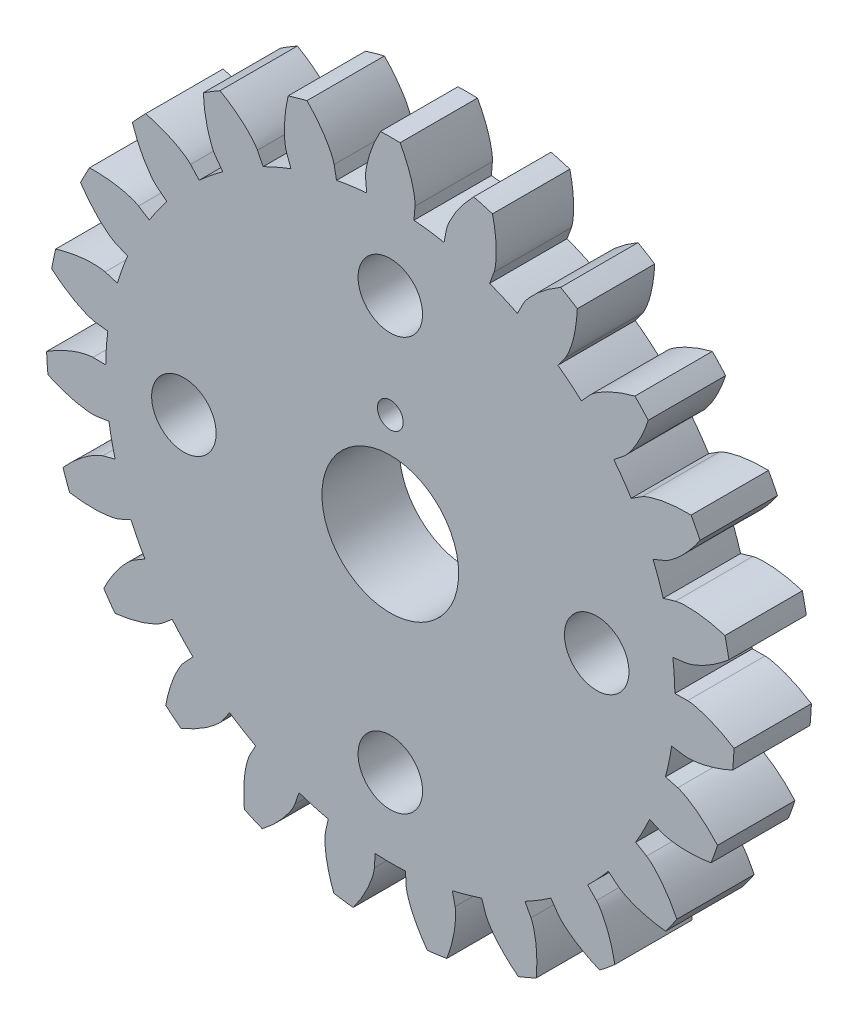
from build123d import *

# Parameters (mm, degrees)
BOSS_EXTRUDE1_DEPTH = 3
SKETCH2_R           = 2.65
SKETCH2_R_2         = 1.25
SKETCH2_R_3         = 0.5
CUT_EXTRUDE1_DEPTH  = 4.0000001


with BuildPart() as part:
    # Model → Boss-Extrude1 (new body)
    with BuildSketch(Plane.XY):
        with BuildLine():
            Line((-3.538746102, -10.448013917), (-3.69731571, -10.916184682))
            add(Edge.make_bspline(
                [(-3.69731571, -10.916184682), (-3.706904602, -10.940308677), (-3.747498158, -11.035961617), (-3.865200891, -11.238603118), (-4.093466254, -11.554754655), (-4.463378416, -11.956665333), (-4.776092769, -12.231743922), (-4.961450629, -12.373903165)],
                knots=[34.58462916, 34.58462916, 34.58462916, 34.58462916, 34.662508722, 34.896108405, 35.285436008, 35.830492648, 36.531278694, 36.531278694, 36.531278694, 36.531278694], degree=3))
            ThreePointArc((-4.961450629, -12.373903165), (-5.31129279, -12.227822405), (-5.656839729, -12.071853054))
            add(Edge.make_bspline(
                [(-5.656839729, -12.071853054), (-5.679461232, -11.839355625), (-5.691868071, -11.423056974), (-5.650622002, -10.878386466), (-5.57537033, -10.495771704), (-5.507611003, -10.271436721), (-5.465411654, -10.176481275), (-5.454325899, -10.153007459)],
                knots=[37.289536731, 37.289536731, 37.289536731, 37.289536731, 37.990322777, 38.535379417, 38.92470702, 39.158306703, 39.236186265, 39.236186265, 39.236186265, 39.236186265], degree=3))
            Line((-5.454325899, -10.153007459), (-5.220402051, -9.717567659))
            ThreePointArc((-5.220402051, -9.717567659), (-5.731548399, -9.425129799), (-6.226360217, -9.105830947))
            Line((-6.226360217, -9.105830947), (-6.505360594, -9.513859102))
            add(Edge.make_bspline(
                [(-6.505360594, -9.513859102), (-6.521102481, -9.534501462), (-6.585997572, -9.615655321), (-6.75400759, -9.779026508), (-7.059104919, -10.02186903), (-7.523733938, -10.309074663), (-7.899067309, -10.489583269), (-8.115905702, -10.576461909)],
                knots=[41.402695863, 41.402695863, 41.402695863, 41.402695863, 41.480575425, 41.714175107, 42.103502711, 42.64855935, 43.349345397, 43.349345397, 43.349345397, 43.349345397], degree=3))
            ThreePointArc((-8.115905702, -10.576461909), (-8.413362649, -10.341411935), (-8.704015743, -10.097998902))
            add(Edge.make_bspline(
                [(-8.704015743, -10.097998902), (-8.663071323, -9.8680199), (-8.562702051, -9.463811408), (-8.376035154, -8.950466815), (-8.200345791, -8.602343105), (-8.074574309, -8.404608319), (-8.008321154, -8.324559327), (-7.991313329, -8.304946884)],
                knots=[44.107603434, 44.107603434, 44.107603434, 44.107603434, 44.80838948, 45.35344612, 45.742773723, 45.976373406, 46.054252968, 46.054252968, 46.054252968, 46.054252968], degree=3))
            Line((-7.991313329, -8.304946884), (-7.64858376, -7.948766272))
            ThreePointArc((-7.64858376, -7.948766272), (-8.061876625, -7.529267167), (-8.452193678, -7.088310152))
            Line((-8.452193678, -7.088310152), (-8.830932644, -7.405934115))
            add(Edge.make_bspline(
                [(-8.830932644, -7.405934115), (-8.85166002, -7.42156389), (-8.936043675, -7.482199858), (-9.141900445, -7.594184238), (-9.501202065, -7.745707227), (-10.026088532, -7.896907086), (-10.436204162, -7.969458212), (-10.668441176, -7.994612858)],
                knots=[48.220762566, 48.220762566, 48.220762566, 48.220762566, 48.298642127, 48.53224181, 48.921569414, 49.466626053, 50.167412099, 50.167412099, 50.167412099, 50.167412099], degree=3))
            ThreePointArc((-10.668441176, -7.994612858), (-10.891451889, -7.688026251), (-11.105654727, -7.375222367))
            add(Edge.make_bspline(
                [(-11.105654727, -7.375222367), (-11.004181046, -7.164818282), (-10.798479592, -6.802678243), (-10.480236096, -6.358731987), (-10.217139118, -6.070918071), (-10.042683378, -5.914448566), (-9.957290109, -5.855242896), (-9.935621607, -5.840946392)],
                knots=[50.925670137, 50.925670137, 50.925670137, 50.925670137, 51.626456183, 52.171512822, 52.560840426, 52.794440109, 52.872319671, 52.872319671, 52.872319671, 52.872319671], degree=3))
            Line((-9.935621607, -5.840946392), (-9.509505001, -5.590441255))
            ThreePointArc((-9.509505001, -5.590441255), (-9.794292341, -5.074993233), (-10.051166601, -4.54508182))
            Line((-10.051166601, -4.54508182), (-10.501554817, -4.748744875))
            add(Edge.make_bspline(
                [(-10.501554817, -4.748744875), (-10.52573043, -4.758202876), (-10.623344298, -4.79382386), (-10.851780364, -4.846116064), (-11.238638519, -4.895081752), (-11.784854006, -4.899062036), (-12.199335495, -4.858274897), (-12.429747173, -4.819839944)],
                knots=[55.038829268, 55.038829268, 55.038829268, 55.038829268, 55.11670883, 55.350308513, 55.739636117, 56.284692756, 56.985478802, 56.985478802, 56.985478802, 56.985478802], degree=3))
            ThreePointArc((-12.429747173, -4.819839944), (-12.561771967, -4.46445483), (-12.683638105, -4.105459328))
            add(Edge.make_bspline(
                [(-12.683638105, -4.105459328), (-12.529161, -3.930234869), (-12.233383301, -3.637021553), (-11.807165871, -3.295399096), (-11.476173977, -3.089240816), (-11.265972562, -2.98564122), (-11.167772409, -2.951669885), (-11.143050283, -2.943749626)],
                knots=[57.74373684, 57.74373684, 57.74373684, 57.74373684, 58.444522886, 58.989579525, 59.378907129, 59.612506812, 59.690386373, 59.690386373, 59.690386373, 59.690386373], degree=3))
            Line((-11.143050283, -2.943749626), (-10.665149759, -2.817498783))
            ThreePointArc((-10.665149759, -2.817498783), (-10.800310201, -2.244330268), (-10.904690477, -1.664765561))
            Line((-10.904690477, -1.664765561), (-11.393324712, -1.739362951))
            add(Edge.make_bspline(
                [(-11.393324712, -1.739362951), (-11.419155565, -1.741947722), (-11.522760073, -1.749911877), (-11.756833378, -1.738633631), (-12.142556567, -1.681410458), (-12.66959077, -1.537875967), (-13.057697923, -1.386775558), (-13.269195685, -1.287601551)],
                knots=[61.856895971, 61.856895971, 61.856895971, 61.856895971, 61.934775533, 62.168375216, 62.557702819, 63.102759459, 63.803545505, 63.803545505, 63.803545505, 63.803545505], degree=3))
            ThreePointArc((-13.269195685, -1.287601551), (-13.300442885, -0.909775217), (-13.320934069, -0.531213152))
            add(Edge.make_bspline(
                [(-13.320934069, -0.531213152), (-13.124910401, -0.404163916), (-12.760992935, -0.201623613), (-12.258412168, 0.012338471), (-11.884073513, 0.121551298), (-11.6537161, 0.164597476), (-11.549992118, 0.170814978), (-11.524049895, 0.171771583)],
                knots=[64.561803542, 64.561803542, 64.561803542, 64.561803542, 65.262589589, 65.807646228, 66.196973832, 66.430573514, 66.508453076, 66.508453076, 66.508453076, 66.508453076], degree=3))
            Line((-11.524049895, 0.171771583), (-11.02980915, 0.164404683))
            ThreePointArc((-11.02980915, 0.164404683), (-11.005318461, 0.752784406), (-10.949463347, 1.339018743))
            Line((-10.949463347, 1.339018743), (-11.440103834, 1.399019565))
            add(Edge.make_bspline(
                [(-11.440103834, 1.399019565), (-11.465674172, 1.403499726), (-11.567585446, 1.423783064), (-11.789935844, 1.497795305), (-12.145916744, 1.656963359), (-12.614681946, 1.937367327), (-12.947630631, 2.18757458), (-13.124528655, 2.340132359)],
                knots=[68.674962674, 68.674962674, 68.674962674, 68.674962674, 68.752842236, 68.986441919, 69.375769522, 69.920826162, 70.621612208, 70.621612208, 70.621612208, 70.621612208], degree=3))
            ThreePointArc((-13.124528655, 2.340132359), (-13.052680799, 2.712378261), (-12.970277292, 3.082430673))
            add(Edge.make_bspline(
                [(-12.970277292, 3.082430673), (-12.747245239, 3.151882026), (-12.342178101, 3.248727828), (-11.800508112, 3.319160949), (-11.410585682, 3.323328508), (-11.177156827, 3.302628731), (-11.07560175, 3.280631276), (-11.050363446, 3.274553279)],
                knots=[71.379870245, 71.379870245, 71.379870245, 71.379870245, 72.080656291, 72.625712931, 73.015040534, 73.248640217, 73.326519779, 73.326519779, 73.326519779, 73.326519779], degree=3))
            Line((-11.050363446, 3.274553279), (-10.576438054, 3.134115007))
            ThreePointArc((-10.576438054, 3.134115007), (-10.394112597, 3.694068504), (-10.182164611, 4.243494152))
            Line((-10.182164611, 4.243494152), (-10.638422789, 4.433643201))
            add(Edge.make_bspline(
                [(-10.638422789, 4.433643201), (-10.661836177, 4.444856019), (-10.754495925, 4.49188253), (-10.948632704, 4.623139615), (-11.248469839, 4.872447783), (-11.624199871, 5.268924949), (-11.877296806, 5.599682319), (-12.006475376, 5.794309358)],
                knots=[75.493029377, 75.493029377, 75.493029377, 75.493029377, 75.570908939, 75.804508621, 76.193836225, 76.738892864, 77.439678911, 77.439678911, 77.439678911, 77.439678911], degree=3))
            ThreePointArc((-12.006475376, 5.794309358), (-11.836861091, 6.133367052), (-11.657674383, 6.467464716))
            add(Edge.make_bspline(
                [(-11.657674383, 6.467464716), (-11.424175213, 6.474167298), (-11.008000378, 6.458135988), (-10.467414354, 6.379816444), (-10.090826911, 6.278629646), (-9.871638964, 6.195719121), (-9.779784667, 6.147138159), (-9.757122092, 6.134476338)],
                knots=[78.197936948, 78.197936948, 78.197936948, 78.197936948, 78.898722994, 79.443779633, 79.833107237, 80.06670692, 80.144586482, 80.144586482, 80.144586482, 80.144586482], degree=3))
            Line((-9.757122092, 6.134476338), (-9.338660931, 5.871382358))
            ThreePointArc((-9.338660931, 5.871382358), (-9.012022951, 6.361380441), (-8.659701306, 6.833249014))
            Line((-8.659701306, 6.833249014), (-9.047738594, 7.139443803))
            add(Edge.make_bspline(
                [(-9.047738594, 7.139443803), (-9.067258567, 7.156557676), (-9.14379464, 7.226839617), (-9.295319562, 7.405606809), (-9.516775385, 7.726565045), (-9.771604069, 8.209710512), (-9.926078213, 8.596487237), (-9.997956744, 8.818748938)],
                knots=[82.31109608, 82.31109608, 82.31109608, 82.31109608, 82.388975641, 82.622575324, 83.011902928, 83.556959567, 84.257745613, 84.257745613, 84.257745613, 84.257745613], degree=3))
            ThreePointArc((-9.997956744, 8.818748938), (-9.743155546, 9.099472067), (-9.480475096, 9.372836489))
            add(Edge.make_bspline(
                [(-9.480475096, 9.372836489), (-9.253826374, 9.316293198), (-8.857409626, 9.188573746), (-8.358000358, 8.967310139), (-8.02267767, 8.768273546), (-7.833986799, 8.629301368), (-7.758645695, 8.557739927), (-7.740239628, 8.539433351)],
                knots=[85.016003651, 85.016003651, 85.016003651, 85.016003651, 85.716789697, 86.261846336, 86.65117394, 86.884773623, 86.962653185, 86.962653185, 86.962653185, 86.962653185], degree=3))
            Line((-7.740239628, 8.539433351), (-7.408278049, 8.173196139))
            ThreePointArc((-7.408278049, 8.173196139), (-6.96155279, 8.556897892), (-6.49498757, 8.916213055))
            Line((-6.49498757, 8.916213055), (-6.786025017, 9.315744518))
            add(Edge.make_bspline(
                [(-6.786025017, 9.315744518), (-6.800203869, 9.337490189), (-6.854939937, 9.42581507), (-6.952615092, 9.638834025), (-7.079265237, 10.007638324), (-7.194293095, 10.541619403), (-7.238687807, 10.955730023), (-7.247935398, 11.189142253)],
                knots=[89.129162782, 89.129162782, 89.129162782, 89.129162782, 89.207042344, 89.440642027, 89.829969631, 90.37502627, 91.075812316, 91.075812316, 91.075812316, 91.075812316], degree=3))
            ThreePointArc((-7.247935398, 11.189142253), (-6.926844725, 11.390710866), (-6.600152341, 11.583067856))
            add(Edge.make_bspline(
                [(-6.600152341, 11.583067856), (-6.397163565, 11.467472251), (-6.049905322, 11.237537024), (-5.628711711, 10.889739464), (-5.359523128, 10.607614709), (-5.215323671, 10.422887809), (-5.162083466, 10.333653274), (-5.149299001, 10.311059658)],
                knots=[91.834070354, 91.834070354, 91.834070354, 91.834070354, 92.5348564, 93.079913039, 93.469240643, 93.702840326, 93.780719887, 93.780719887, 93.780719887, 93.780719887], degree=3))
            Line((-5.149299001, 10.311059658), (-4.928457074, 9.868841353))
            ThreePointArc((-4.928457074, 9.868841353), (-4.394776106, 10.117789371), (-3.848570319, 10.337902364))
            Line((-3.848570319, 10.337902364), (-4.02102301, 10.80113908))
            add(Edge.make_bspline(
                [(-4.02102301, 10.80113908), (-4.02880916, 10.82590377), (-4.057685698, 10.925720939), (-4.094266967, 11.157193015), (-4.116718371, 11.546490851), (-4.083414314, 12.091704607), (-4.014437041, 12.502436432), (-3.96036784, 12.729688074)],
                knots=[95.947229485, 95.947229485, 95.947229485, 95.947229485, 96.025109047, 96.25870873, 96.648036333, 97.193092973, 97.893879019, 97.893879019, 97.893879019, 97.893879019], degree=3))
            ThreePointArc((-3.96036784, 12.729688074), (-3.59680152, 12.837152749), (-3.23032648, 12.93423607))
            add(Edge.make_bspline(
                [(-3.23032648, 12.93423607), (-3.066052401, 12.768161347), (-2.793707216, 12.453063589), (-2.481967266, 12.00452663), (-2.298877274, 11.660237616), (-2.209863845, 11.443456342), (-2.18267312, 11.34316683), (-2.176458423, 11.31796184)],
                knots=[98.652137056, 98.652137056, 98.652137056, 98.652137056, 99.352923103, 99.897979742, 100.287307346, 100.520907028, 100.59878659, 100.59878659, 100.59878659, 100.59878659], degree=3))
            Line((-2.176458423, 11.31796184), (-2.083114985, 10.83255975))
            ThreePointArc((-2.083114985, 10.83255975), (-1.502058983, 10.928290699), (-0.916722213, 10.992876747))
            Line((-0.916722213, 10.992876747), (-0.95780012, 11.485462568))
            add(Edge.make_bspline(
                [(-0.95780012, 11.485462568), (-0.958616105, 11.511409594), (-0.959491473, 11.615316069), (-0.932265791, 11.848074041), (-0.848853337, 12.228992973), (-0.669687373, 12.745003397), (-0.492453845, 13.121894326), (-0.379077917, 13.326131165)],
                knots=[102.765296188, 102.765296188, 102.765296188, 102.765296188, 102.84317575, 103.076775433, 103.466103036, 104.011159676, 104.711945722, 104.711945722, 104.711945722, 104.711945722], degree=3))
            ThreePointArc((-0.379077917, 13.326131165), (0, 13.331521739), (0.379077917, 13.326131165))
            add(Edge.make_bspline(
                [(0.379077917, 13.326131165), (0.492453845, 13.121894326), (0.669687373, 12.745003397), (0.848853337, 12.228992973), (0.932265791, 11.848074041), (0.959491473, 11.615316069), (0.958616105, 11.511409594), (0.95780012, 11.485462568)],
                knots=[105.470203759, 105.470203759, 105.470203759, 105.470203759, 106.170989805, 106.716046445, 107.105374048, 107.338973731, 107.416853293, 107.416853293, 107.416853293, 107.416853293], degree=3))
            Line((0.95780012, 11.485462568), (0.916722213, 10.992876747))
            ThreePointArc((0.916722213, 10.992876747), (1.502058983, 10.928290699), (2.083114985, 10.83255975))
            Line((2.083114985, 10.83255975), (2.176458423, 11.31796184))
            add(Edge.make_bspline(
                [(2.176458423, 11.31796184), (2.18267312, 11.34316683), (2.209863845, 11.443456342), (2.298877274, 11.660237616), (2.481967266, 12.00452663), (2.793707216, 12.453063589), (3.066052401, 12.768161347), (3.23032648, 12.93423607)],
                knots=[109.583362891, 109.583362891, 109.583362891, 109.583362891, 109.661242453, 109.894842135, 110.284169739, 110.829226378, 111.530012424, 111.530012424, 111.530012424, 111.530012424], degree=3))
            ThreePointArc((3.23032648, 12.93423607), (3.59680152, 12.837152749), (3.96036784, 12.729688074))
            add(Edge.make_bspline(
                [(3.96036784, 12.729688074), (4.014437041, 12.502436432), (4.083414314, 12.091704607), (4.116718371, 11.546490851), (4.094266967, 11.157193015), (4.057685698, 10.925720939), (4.02880916, 10.82590377), (4.02102301, 10.80113908)],
                knots=[112.288270462, 112.288270462, 112.288270462, 112.288270462, 112.989056508, 113.534113147, 113.923440751, 114.157040434, 114.234919996, 114.234919996, 114.234919996, 114.234919996], degree=3))
            Line((4.02102301, 10.80113908), (3.848570319, 10.337902364))
            ThreePointArc((3.848570319, 10.337902364), (4.394776106, 10.117789371), (4.928457074, 9.868841353))
            Line((4.928457074, 9.868841353), (5.149299001, 10.311059658))
            add(Edge.make_bspline(
                [(5.149299001, 10.311059658), (5.162083466, 10.333653274), (5.215323671, 10.422887809), (5.359523128, 10.607614709), (5.628711711, 10.889739464), (6.049905322, 11.237537024), (6.397163565, 11.467472251), (6.600152341, 11.583067856)],
                knots=[116.401429594, 116.401429594, 116.401429594, 116.401429594, 116.479309155, 116.712908838, 117.102236442, 117.647293081, 118.348079127, 118.348079127, 118.348079127, 118.348079127], degree=3))
            ThreePointArc((6.600152341, 11.583067856), (6.926844725, 11.390710866), (7.247935398, 11.189142253))
            add(Edge.make_bspline(
                [(7.247935398, 11.189142253), (7.238687807, 10.955730023), (7.194293095, 10.541619403), (7.079265237, 10.007638324), (6.952615092, 9.638834025), (6.854939937, 9.42581507), (6.800203869, 9.337490189), (6.786025017, 9.315744518)],
                knots=[119.106337165, 119.106337165, 119.106337165, 119.106337165, 119.807123211, 120.35217985, 120.741507454, 120.975107137, 121.052986698, 121.052986698, 121.052986698, 121.052986698], degree=3))
            Line((6.786025017, 9.315744518), (6.49498757, 8.916213055))
            ThreePointArc((6.49498757, 8.916213055), (6.96155279, 8.556897892), (7.408278049, 8.173196139))
            Line((7.408278049, 8.173196139), (7.740239628, 8.539433351))
            add(Edge.make_bspline(
                [(7.740239628, 8.539433351), (7.758645695, 8.557739927), (7.833986799, 8.629301368), (8.02267767, 8.768273546), (8.358000358, 8.967310139), (8.857409626, 9.188573746), (9.253826374, 9.316293198), (9.480475096, 9.372836489)],
                knots=[123.219496296, 123.219496296, 123.219496296, 123.219496296, 123.297375858, 123.530975541, 123.920303145, 124.465359784, 125.16614583, 125.16614583, 125.16614583, 125.16614583], degree=3))
            ThreePointArc((9.480475096, 9.372836489), (9.743155546, 9.099472067), (9.997956744, 8.818748938))
            add(Edge.make_bspline(
                [(9.997956744, 8.818748938), (9.926078213, 8.596487237), (9.771604069, 8.209710512), (9.516775385, 7.726565045), (9.295319562, 7.405606809), (9.14379464, 7.226839617), (9.067258567, 7.156557676), (9.047738594, 7.139443803)],
                knots=[125.924403868, 125.924403868, 125.924403868, 125.924403868, 126.625189914, 127.170246553, 127.559574157, 127.79317384, 127.871053401, 127.871053401, 127.871053401, 127.871053401], degree=3))
            Line((9.047738594, 7.139443803), (8.659701306, 6.833249014))
            ThreePointArc((8.659701306, 6.833249014), (9.012022951, 6.361380441), (9.338660931, 5.871382358))
            Line((9.338660931, 5.871382358), (9.757122092, 6.134476338))
            add(Edge.make_bspline(
                [(9.757122092, 6.134476338), (9.779784667, 6.147138159), (9.871638964, 6.195719121), (10.090826911, 6.278629646), (10.467414354, 6.379816444), (11.008000378, 6.458135988), (11.424175213, 6.474167298), (11.657674383, 6.467464716)],
                knots=[130.037562999, 130.037562999, 130.037562999, 130.037562999, 130.115442561, 130.349042244, 130.738369847, 131.283426487, 131.984212533, 131.984212533, 131.984212533, 131.984212533], degree=3))
            ThreePointArc((11.657674383, 6.467464716), (11.836861091, 6.133367052), (12.006475376, 5.794309358))
            add(Edge.make_bspline(
                [(12.006475376, 5.794309358), (11.877296806, 5.599682319), (11.624199871, 5.268924949), (11.248469839, 4.872447783), (10.948632704, 4.623139615), (10.754495925, 4.49188253), (10.661836177, 4.444856019), (10.638422789, 4.433643201)],
                knots=[132.74247057, 132.74247057, 132.74247057, 132.74247057, 133.443256617, 133.988313256, 134.37764086, 134.611240542, 134.689120104, 134.689120104, 134.689120104, 134.689120104], degree=3))
            Line((10.638422789, 4.433643201), (10.182164611, 4.243494152))
            ThreePointArc((10.182164611, 4.243494152), (10.394112597, 3.694068504), (10.576438054, 3.134115007))
            Line((10.576438054, 3.134115007), (11.050363446, 3.274553279))
            add(Edge.make_bspline(
                [(11.050363446, 3.274553279), (11.07560175, 3.280631276), (11.177156827, 3.302628731), (11.410585682, 3.323328508), (11.800508112, 3.319160949), (12.342178101, 3.248727828), (12.747245239, 3.151882026), (12.970277292, 3.082430673)],
                knots=[136.855629702, 136.855629702, 136.855629702, 136.855629702, 136.933509264, 137.167108946, 137.55643655, 138.101493189, 138.802279236, 138.802279236, 138.802279236, 138.802279236], degree=3))
            ThreePointArc((12.970277292, 3.082430673), (13.052680799, 2.712378261), (13.124528655, 2.340132359))
            add(Edge.make_bspline(
                [(13.124528655, 2.340132359), (12.947630631, 2.18757458), (12.614681946, 1.937367327), (12.145916744, 1.656963359), (11.789935844, 1.497795305), (11.567585446, 1.423783064), (11.465674172, 1.403499726), (11.440103834, 1.399019565)],
                knots=[139.560537273, 139.560537273, 139.560537273, 139.560537273, 140.261323319, 140.806379959, 141.195707562, 141.429307245, 141.507186807, 141.507186807, 141.507186807, 141.507186807], degree=3))
            Line((11.440103834, 1.399019565), (10.949463347, 1.339018743))
            ThreePointArc((10.949463347, 1.339018743), (11.005318461, 0.752784406), (11.02980915, 0.164404683))
            Line((11.02980915, 0.164404683), (11.524049895, 0.171771583))
            add(Edge.make_bspline(
                [(11.524049895, 0.171771583), (11.549992118, 0.170814978), (11.6537161, 0.164597476), (11.884073513, 0.121551298), (12.258412168, 0.012338471), (12.760992935, -0.201623613), (13.124910401, -0.404163916), (13.320934069, -0.531213152)],
                knots=[143.673696405, 143.673696405, 143.673696405, 143.673696405, 143.751575967, 143.985175649, 144.374503253, 144.919559892, 145.620345938, 145.620345938, 145.620345938, 145.620345938], degree=3))
            ThreePointArc((13.320934069, -0.531213152), (13.300442885, -0.909775217), (13.269195685, -1.287601551))
            add(Edge.make_bspline(
                [(13.269195685, -1.287601551), (13.057697923, -1.386775558), (12.66959077, -1.537875967), (12.142556567, -1.681410458), (11.756833378, -1.738633631), (11.522760073, -1.749911877), (11.419155565, -1.741947722), (11.393324712, -1.739362951)],
                knots=[146.378603976, 146.378603976, 146.378603976, 146.378603976, 147.079390022, 147.624446661, 148.013774265, 148.247373948, 148.32525351, 148.32525351, 148.32525351, 148.32525351], degree=3))
            Line((11.393324712, -1.739362951), (10.904690477, -1.664765561))
            ThreePointArc((10.904690477, -1.664765561), (10.800310201, -2.244330268), (10.665149759, -2.817498783))
            Line((10.665149759, -2.817498783), (11.143050283, -2.943749626))
            add(Edge.make_bspline(
                [(11.143050283, -2.943749626), (11.167772409, -2.951669885), (11.265972562, -2.98564122), (11.476173977, -3.089240816), (11.807165871, -3.295399096), (12.233383301, -3.637021553), (12.529161, -3.930234869), (12.683638105, -4.105459328)],
                knots=[150.491763108, 150.491763108, 150.491763108, 150.491763108, 150.569642669, 150.803242352, 151.192569956, 151.737626595, 152.438412641, 152.438412641, 152.438412641, 152.438412641], degree=3))
            ThreePointArc((12.683638105, -4.105459328), (12.561771967, -4.46445483), (12.429747173, -4.819839944))
            add(Edge.make_bspline(
                [(12.429747173, -4.819839944), (12.199335495, -4.858274897), (11.784854006, -4.899062036), (11.238638519, -4.895081752), (10.851780364, -4.846116064), (10.623344298, -4.79382386), (10.52573043, -4.758202876), (10.501554817, -4.748744875)],
                knots=[153.196670679, 153.196670679, 153.196670679, 153.196670679, 153.897456725, 154.442513364, 154.831840968, 155.065440651, 155.143320212, 155.143320212, 155.143320212, 155.143320212], degree=3))
            Line((10.501554817, -4.748744875), (10.051166601, -4.54508182))
            ThreePointArc((10.051166601, -4.54508182), (9.794292341, -5.074993233), (9.509505001, -5.590441255))
            Line((9.509505001, -5.590441255), (9.935621607, -5.840946392))
            add(Edge.make_bspline(
                [(9.935621607, -5.840946392), (9.957290109, -5.855242896), (10.042683378, -5.914448566), (10.217139118, -6.070918071), (10.480236096, -6.358731987), (10.798479592, -6.802678243), (11.004181046, -7.164818282), (11.105654727, -7.375222367)],
                knots=[157.30982981, 157.30982981, 157.30982981, 157.30982981, 157.387709372, 157.621309055, 158.010636659, 158.555693298, 159.256479344, 159.256479344, 159.256479344, 159.256479344], degree=3))
            ThreePointArc((11.105654727, -7.375222367), (10.891451889, -7.688026251), (10.668441176, -7.994612858))
            add(Edge.make_bspline(
                [(10.668441176, -7.994612858), (10.436204162, -7.969458212), (10.026088532, -7.896907086), (9.501202065, -7.745707227), (9.141900445, -7.594184238), (8.936043675, -7.482199858), (8.85166002, -7.42156389), (8.830932644, -7.405934115)],
                knots=[160.014737382, 160.014737382, 160.014737382, 160.014737382, 160.715523428, 161.260580067, 161.649907671, 161.883507354, 161.961386915, 161.961386915, 161.961386915, 161.961386915], degree=3))
            Line((8.830932644, -7.405934115), (8.452193678, -7.088310152))
            ThreePointArc((8.452193678, -7.088310152), (8.061876625, -7.529267167), (7.64858376, -7.948766272))
            Line((7.64858376, -7.948766272), (7.991313329, -8.304946884))
            add(Edge.make_bspline(
                [(7.991313329, -8.304946884), (8.008321154, -8.324559327), (8.074574309, -8.404608319), (8.200345791, -8.602343105), (8.376035154, -8.950466815), (8.562702051, -9.463811408), (8.663071323, -9.8680199), (8.704015743, -10.097998902)],
                knots=[164.127896513, 164.127896513, 164.127896513, 164.127896513, 164.205776075, 164.439375758, 164.828703361, 165.373760001, 166.074546047, 166.074546047, 166.074546047, 166.074546047], degree=3))
            ThreePointArc((8.704015743, -10.097998902), (8.413362649, -10.341411935), (8.115905702, -10.576461909))
            add(Edge.make_bspline(
                [(8.115905702, -10.576461909), (7.899067309, -10.489583269), (7.523733938, -10.309074663), (7.059104919, -10.02186903), (6.75400759, -9.779026508), (6.585997572, -9.615655321), (6.521102481, -9.534501462), (6.505360594, -9.513859102)],
                knots=[166.832804084, 166.832804084, 166.832804084, 166.832804084, 167.533590131, 168.07864677, 168.467974374, 168.701574056, 168.779453618, 168.779453618, 168.779453618, 168.779453618], degree=3))
            Line((6.505360594, -9.513859102), (6.226360217, -9.105830947))
            ThreePointArc((6.226360217, -9.105830947), (5.731548399, -9.425129799), (5.220402051, -9.717567659))
            Line((5.220402051, -9.717567659), (5.454325899, -10.153007459))
            add(Edge.make_bspline(
                [(5.454325899, -10.153007459), (5.465411654, -10.176481275), (5.507611003, -10.271436721), (5.57537033, -10.495771704), (5.650622002, -10.878386466), (5.691868071, -11.423056974), (5.679461232, -11.839355625), (5.656839729, -12.071853054)],
                knots=[170.945963216, 170.945963216, 170.945963216, 170.945963216, 171.023842778, 171.25744246, 171.646770064, 172.191826703, 172.89261275, 172.89261275, 172.89261275, 172.89261275], degree=3))
            ThreePointArc((5.656839729, -12.071853054), (5.31129279, -12.227822405), (4.961450629, -12.373903165))
            add(Edge.make_bspline(
                [(4.961450629, -12.373903165), (4.776092769, -12.231743922), (4.463378416, -11.956665333), (4.093466254, -11.554754655), (3.865200891, -11.238603118), (3.747498158, -11.035961617), (3.706904602, -10.940308677), (3.69731571, -10.916184682)],
                knots=[173.650870787, 173.650870787, 173.650870787, 173.650870787, 174.351656833, 174.896713473, 175.286041076, 175.519640759, 175.597520321, 175.597520321, 175.597520321, 175.597520321], degree=3))
            Line((3.69731571, -10.916184682), (3.538746102, -10.448013917))
            ThreePointArc((3.538746102, -10.448013917), (2.97613745, -10.621973671), (2.405047004, -10.765661507))
            Line((2.405047004, -10.765661507), (2.512816069, -11.248065917))
            add(Edge.make_bspline(
                [(2.512816069, -11.248065917), (2.517157574, -11.273660161), (2.532173385, -11.37647965), (2.536895158, -11.610776931), (2.506128066, -11.999505958), (2.398894274, -12.535106662), (2.274631483, -12.932620505), (2.190121791, -13.15039309)],
                knots=[177.764029919, 177.764029919, 177.764029919, 177.764029919, 177.841909481, 178.075509163, 178.464836767, 179.009893406, 179.710679452, 179.710679452, 179.710679452, 179.710679452], degree=3))
            ThreePointArc((2.190121791, -13.15039309), (1.815308643, -13.207351226), (1.439027461, -13.253628629))
            add(Edge.make_bspline(
                [(1.439027461, -13.253628629), (1.298897277, -13.066732084), (1.071994537, -12.717484833), (0.824233924, -12.230676987), (0.689729923, -11.864663948), (0.63106395, -11.637781127), (0.617782568, -11.534723247), (0.615057833, -11.508906783)],
                knots=[180.46893749, 180.46893749, 180.46893749, 180.46893749, 181.169723536, 181.714780175, 182.104107779, 182.337707462, 182.415587024, 182.415587024, 182.415587024, 182.415587024], degree=3))
            Line((0.615057833, -11.508906783), (0.588679377, -11.015315491))
            ThreePointArc((0.588679377, -11.015315491), (0, -11.031034348), (-0.588679377, -11.015315491))
            Line((-0.588679377, -11.015315491), (-0.615057833, -11.508906783))
            add(Edge.make_bspline(
                [(-0.615057833, -11.508906783), (-0.617782568, -11.534723247), (-0.63106395, -11.637781127), (-0.689729923, -11.864663948), (-0.824233924, -12.230676987), (-1.071994537, -12.717484833), (-1.298897277, -13.066732084), (-1.439027461, -13.253628629)],
                knots=[184.582096622, 184.582096622, 184.582096622, 184.582096622, 184.659976183, 184.893575866, 185.28290347, 185.827960109, 186.528746155, 186.528746155, 186.528746155, 186.528746155], degree=3))
            ThreePointArc((-1.439027461, -13.253628629), (-1.815308643, -13.207351226), (-2.190121791, -13.15039309))
            add(Edge.make_bspline(
                [(-2.190121791, -13.15039309), (-2.274631483, -12.932620505), (-2.398894274, -12.535106662), (-2.506128066, -11.999505958), (-2.536895158, -11.610776931), (-2.532173385, -11.37647965), (-2.517157574, -11.273660161), (-2.512816069, -11.248065917)],
                knots=[187.287004193, 187.287004193, 187.287004193, 187.287004193, 187.987790239, 188.532846878, 188.922174482, 189.155774165, 189.233653726, 189.233653726, 189.233653726, 189.233653726], degree=3))
            Line((-2.512816069, -11.248065917), (-2.405047004, -10.765661507))
            ThreePointArc((-2.405047004, -10.765661507), (-2.97613745, -10.621973671), (-3.538746102, -10.448013917))
        make_face()
    extrude(amount=BOSS_EXTRUDE1_DEPTH)

    # Sketch2 → Cut-Extrude1 (cut, through all)
    with BuildSketch(Plane.XY):
        Circle(SKETCH2_R)
        with Locations((0, 8)):
            Circle(SKETCH2_R_2)
        with Locations((-8, 0)):
            Circle(SKETCH2_R_2)
        with Locations((0, -8)):
            Circle(SKETCH2_R_2)
        with Locations((8, 0)):
            Circle(SKETCH2_R_2)
        with Locations((0, 4)):
            Circle(SKETCH2_R_3)
    extrude(amount=CUT_EXTRUDE1_DEPTH, mode=Mode.SUBTRACT)


solid = part.part
